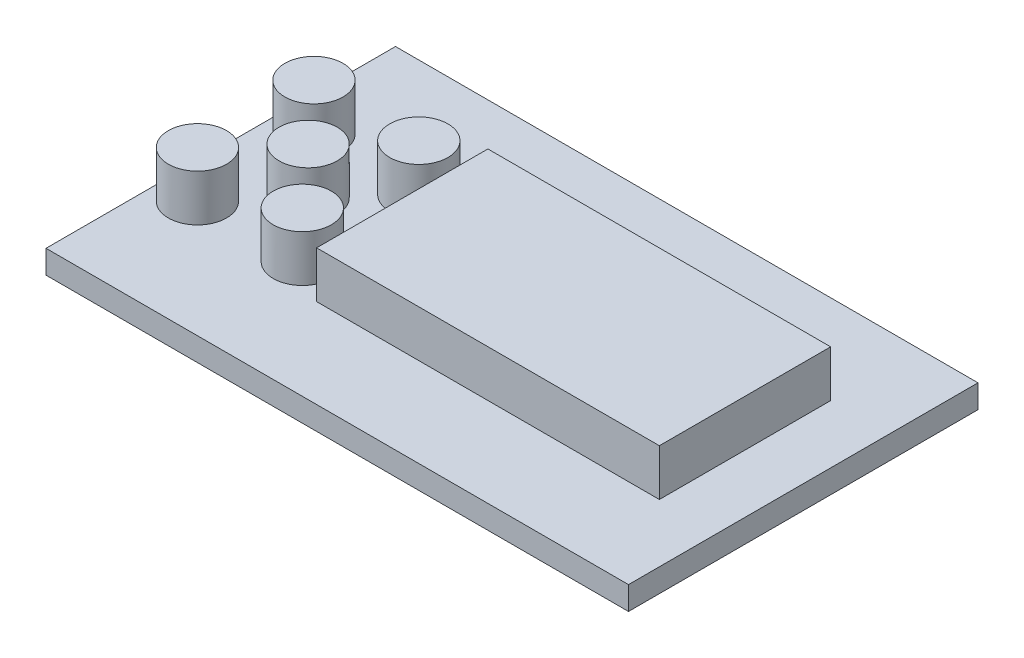
from build123d import *

# Parameters (mm, degrees)
SKETCH_1_W      = 50
SKETCH_1_H      = 30
EXTRUDE_1_DEPTH = 2
SKETCH_2_W      = 29.42
SKETCH_2_H      = 14.7
EXTRUDE_2_DEPTH = 4
SKETCH_3_W      = 24
SKETCH_3_H      = 15
EXTRUDE_3_DEPTH = 1
SKETCH_4_W      = 16
SKETCH_4_H      = 13
EXTRUDE_4_DEPTH = 2
SKETCH_5_R      = 2.5
EXTRUDE_5_DEPTH = 4


with BuildPart() as part:
    # 草图1 → 凸台-拉伸1 (new body)
    with BuildSketch(Plane(origin=(0, 0, 0), x_dir=(1, 0, 0), z_dir=(0, 1, 0))):
        Rectangle(SKETCH_1_W, SKETCH_1_H)
    extrude(amount=EXTRUDE_1_DEPTH)

    # 草图2 → 凸台-拉伸2 (add)
    with BuildSketch(Plane(origin=(0, 2, 0), x_dir=(1, 0, 0), z_dir=(0, 1, 0))):
        with Locations((5.29, 0)):
            Rectangle(SKETCH_2_W, SKETCH_2_H)
    extrude(amount=EXTRUDE_2_DEPTH)

    # 草图3 → 凸台-拉伸3 (add)
    with BuildSketch(Plane(origin=(0, 0, 0), x_dir=(-1, 0, 0), z_dir=(0, -1, 0))):
        with Locations((-12, 0)):
            Rectangle(SKETCH_3_W, SKETCH_3_H)
    extrude(amount=EXTRUDE_3_DEPTH)

    # 草图4 → 凸台-拉伸4 (add)
    with BuildSketch(Plane.XZ.offset(1)):
        with Locations((9, 0)):
            Rectangle(SKETCH_4_W, SKETCH_4_H)
    extrude(amount=EXTRUDE_4_DEPTH)

    # 草图5 → 凸台-拉伸5 (add)
    with BuildSketch(Plane(origin=(0, 2, 0), x_dir=(1, 0, 0), z_dir=(0, 1, 0))):
        with Locations((-22, 5)):
            Circle(SKETCH_5_R)
        with Locations((-22, -5)):
            Circle(SKETCH_5_R)
        with Locations((-13, -5)):
            Circle(SKETCH_5_R)
        with Locations((-13, 5)):
            Circle(SKETCH_5_R)
        with Locations((-17.5, 0)):
            Circle(SKETCH_5_R)
    extrude(amount=EXTRUDE_5_DEPTH)


solid = part.part
